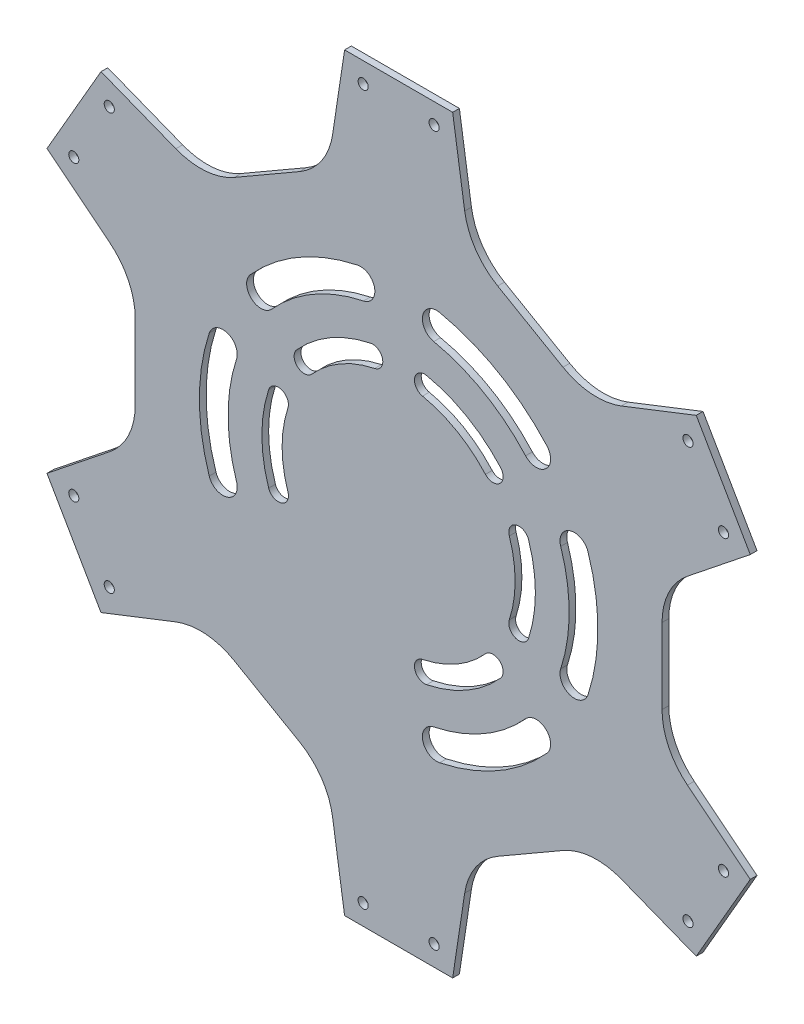
from build123d import *

# Parameters (mm, degrees)
BOSS_EXTRUDE1_DEPTH = 2
CUT_EXTRUDE4_REACH  = 4
CUT_EXTRUDE5_REACH  = 4
SKETCH6_R           = 1.5


with BuildPart() as part:
    # Sketch1 → Boss-Extrude1 (new body)
    with BuildSketch(Plane.XY):
        with BuildLine():
            Line((88.12881982, 222), (84.568261253, 198.459214885))
            ThreePointArc((84.568261253, 198.459214885), (81.315061134, 190.17956792), (74.793177049, 184.129700743))
            Line((74.793177049, 184.129700743), (55.464462591, 172.970262248))
            ThreePointArc((55.464462591, 172.970262248), (46.964181884, 170.347078538), (38.167197219, 171.669548074))
            Line((38.167197219, 171.669548074), (16, 180.356406461))
            Line((16, 180.356406461), (0, 152.643593539))
            Line((0, 152.643593539), (18.606638651, 137.789666811))
            ThreePointArc((18.606638651, 137.789666811), (24.150423198, 130.832489382), (26.12881982, 122.159438495))
            Line((26.12881982, 122.159438495), (26.12881982, 99.840561505))
            ThreePointArc((26.12881982, 99.840561505), (24.150423198, 91.167510618), (18.606638651, 84.210333189))
            Line((18.606638651, 84.210333189), (0, 69.356406461))
            Line((0, 69.356406461), (16, 41.643593539))
            Line((16, 41.643593539), (38.167197219, 50.330451926))
            ThreePointArc((38.167197219, 50.330451926), (46.964181884, 51.652921462), (55.464462591, 49.029737752))
            Line((55.464462591, 49.029737752), (74.793177049, 37.870299257))
            ThreePointArc((74.793177049, 37.870299257), (81.315061134, 31.82043208), (84.568261253, 23.540785115))
            Line((84.568261253, 23.540785115), (88.12881982, 0))
            Line((88.12881982, 0), (120.12881982, 0))
            Line((120.12881982, 0), (123.689378387, 23.540785115))
            ThreePointArc((123.689378387, 23.540785115), (126.942578506, 31.82043208), (133.464462591, 37.870299257))
            Line((133.464462591, 37.870299257), (152.793177049, 49.029737752))
            ThreePointArc((152.793177049, 49.029737752), (161.293457756, 51.652921462), (170.090442422, 50.330451926))
            Line((170.090442422, 50.330451926), (192.25763964, 41.643593539))
            Line((192.25763964, 41.643593539), (208.25763964, 69.356406461))
            Line((208.25763964, 69.356406461), (189.651000989, 84.210333189))
            ThreePointArc((189.651000989, 84.210333189), (184.107216442, 91.167510618), (182.12881982, 99.840561505))
            Line((182.12881982, 99.840561505), (182.12881982, 122.159438495))
            ThreePointArc((182.12881982, 122.159438495), (184.107216442, 130.832489382), (189.651000989, 137.789666811))
            Line((189.651000989, 137.789666811), (208.25763964, 152.643593539))
            Line((208.25763964, 152.643593539), (192.25763964, 180.356406461))
            Line((192.25763964, 180.356406461), (170.090442422, 171.669548074))
            ThreePointArc((170.090442422, 171.669548074), (161.293457756, 170.347078538), (152.793177049, 172.970262248))
            Line((152.793177049, 172.970262248), (133.464462591, 184.129700743))
            ThreePointArc((133.464462591, 184.129700743), (126.942578506, 190.17956792), (123.689378387, 198.459214885))
            Line((123.689378387, 198.459214885), (120.12881982, 222))
            Line((120.12881982, 222), (88.12881982, 222))
        make_face()
    extrude(amount=BOSS_EXTRUDE1_DEPTH)

    # Sketch5 → Cut-Extrude4 (cut, up to next)
    with BuildSketch(Plane.XY.offset(2), mode=Mode.PRIVATE) as cut_extrude4_sk1:
        with BuildLine():
            ThreePointArc((134.30285859, 138.01439217), (124.37881982, 146.074028853), (112.436950322, 150.638680195))
            ThreePointArc((112.436950322, 150.638680195), (108.885334715, 148.317898736), (111.206116174, 144.766283129))
            ThreePointArc((111.206116174, 144.766283129), (121.37881982, 140.877876431), (129.832630624, 134.012259997))
            ThreePointArc((129.832630624, 134.012259997), (134.068810694, 133.7782121), (134.30285859, 138.01439217))
        make_face()
    cut_extrude4_tool1 = extrude(cut_extrude4_sk1.sketch, amount=-CUT_EXTRUDE4_REACH, mode=Mode.PRIVATE) & part.part
    add(cut_extrude4_tool1.solids().sort_by_distance((122.463529, 142.756648, 2))[0], mode=Mode.SUBTRACT)
    # Sketch5 → Cut-Extrude4 (cut, up to next)
    with BuildSketch(Plane.XY.offset(2), mode=Mode.PRIVATE) as cut_extrude4_sk2:
        with BuildLine():
            ThreePointArc((116.289083676, 168.733248505), (111.254381514, 165.450448764), (114.537181256, 160.415746602))
            ThreePointArc((114.537181256, 160.415746602), (129.37881982, 154.734282891), (141.719931007, 144.721778716))
            ThreePointArc((141.719931007, 144.721778716), (147.72151085, 144.396141825), (148.047147741, 150.397721668))
            ThreePointArc((148.047147741, 150.397721668), (133.62881982, 162.095498823), (116.289083676, 168.733248505))
        make_face()
    cut_extrude4_tool2 = extrude(cut_extrude4_sk2.sketch, amount=-CUT_EXTRUDE4_REACH, mode=Mode.PRIVATE) & part.part
    add(cut_extrude4_tool2.solids().sort_by_distance((130.90458, 157.376977, 2))[0], mode=Mode.SUBTRACT)
    # Sketch5 → Cut-Extrude4 (cut, up to next)
    with BuildSketch(Plane.XY.offset(2), mode=Mode.PRIVATE) as cut_extrude4_sk3:
        with BuildLine():
            ThreePointArc((136.909926978, 100.245976868), (138.62881982, 111), (136.909926978, 121.754023132))
            ThreePointArc((136.909926978, 121.754023132), (138.825325589, 125.539686636), (142.610989092, 123.624288025))
            ThreePointArc((142.610989092, 123.624288025), (144.62881982, 111), (142.610989092, 98.375711975))
            ThreePointArc((142.610989092, 98.375711975), (138.825325589, 96.460313364), (136.909926978, 100.245976868))
        make_face()
    cut_extrude4_tool3 = extrude(cut_extrude4_sk3.sketch, amount=-CUT_EXTRUDE4_REACH, mode=Mode.PRIVATE) & part.part
    add(cut_extrude4_tool3.solids().sort_by_distance((140.798238, 111, 2))[0], mode=Mode.SUBTRACT)
    # Sketch5 → Cut-Extrude4 (cut, up to next)
    with BuildSketch(Plane.XY.offset(2), mode=Mode.PRIVATE) as cut_extrude4_sk4:
        with BuildLine():
            ThreePointArc((152.128292442, 95.306032114), (154.62881982, 111), (152.128292442, 126.693967886))
            ThreePointArc((152.128292442, 126.693967886), (154.847072544, 132.054306939), (160.207411596, 129.335526837))
            ThreePointArc((160.207411596, 129.335526837), (163.12881982, 111), (160.207411596, 92.664473163))
            ThreePointArc((160.207411596, 92.664473163), (154.847072544, 89.945693061), (152.128292442, 95.306032114))
        make_face()
    cut_extrude4_tool4 = extrude(cut_extrude4_sk4.sketch, amount=-CUT_EXTRUDE4_REACH, mode=Mode.PRIVATE) & part.part
    add(cut_extrude4_tool4.solids().sort_by_distance((157.68034, 111, 2))[0], mode=Mode.SUBTRACT)
    # Sketch5 → Cut-Extrude4 (cut, up to next)
    with BuildSketch(Plane.XY.offset(2), mode=Mode.PRIVATE) as cut_extrude4_sk5:
        with BuildLine():
            ThreePointArc((111.206116174, 77.233716871), (121.37881982, 81.122123569), (129.832630624, 87.987740003))
            ThreePointArc((129.832630624, 87.987740003), (134.068810694, 88.2217879), (134.30285859, 83.98560783))
            ThreePointArc((134.30285859, 83.98560783), (124.37881982, 75.925971147), (112.436950322, 71.361319805))
            ThreePointArc((112.436950322, 71.361319805), (108.885334715, 73.682101264), (111.206116174, 77.233716871))
        make_face()
    cut_extrude4_tool5 = extrude(cut_extrude4_sk5.sketch, amount=-CUT_EXTRUDE4_REACH, mode=Mode.PRIVATE) & part.part
    add(cut_extrude4_tool5.solids().sort_by_distance((122.463529, 79.243352, 2))[0], mode=Mode.SUBTRACT)
    # Sketch5 → Cut-Extrude4 (cut, up to next)
    with BuildSketch(Plane.XY.offset(2), mode=Mode.PRIVATE) as cut_extrude4_sk6:
        with BuildLine():
            ThreePointArc((114.537181256, 61.584253398), (129.37881982, 67.265717109), (141.719931007, 77.278221284))
            ThreePointArc((141.719931007, 77.278221284), (147.72151085, 77.603858175), (148.047147741, 71.602278332))
            ThreePointArc((148.047147741, 71.602278332), (133.62881982, 59.904501177), (116.289083676, 53.266751495))
            ThreePointArc((116.289083676, 53.266751495), (111.254381514, 56.549551236), (114.537181256, 61.584253398))
        make_face()
    cut_extrude4_tool6 = extrude(cut_extrude4_sk6.sketch, amount=-CUT_EXTRUDE4_REACH, mode=Mode.PRIVATE) & part.part
    add(cut_extrude4_tool6.solids().sort_by_distance((130.90458, 64.623023, 2))[0], mode=Mode.SUBTRACT)
    # Sketch5 → Cut-Extrude4 (cut, up to next)
    with BuildSketch(Plane.XY.offset(2), mode=Mode.PRIVATE) as cut_extrude4_sk7:
        with BuildLine():
            ThreePointArc((71.347712663, 121.754023132), (69.62881982, 111), (71.347712663, 100.245976868))
            ThreePointArc((71.347712663, 100.245976868), (69.432314052, 96.460313364), (65.646650548, 98.375711975))
            ThreePointArc((65.646650548, 98.375711975), (63.62881982, 111), (65.646650548, 123.624288025))
            ThreePointArc((65.646650548, 123.624288025), (69.432314052, 125.539686636), (71.347712663, 121.754023132))
        make_face()
    cut_extrude4_tool7 = extrude(cut_extrude4_sk7.sketch, amount=-CUT_EXTRUDE4_REACH, mode=Mode.PRIVATE) & part.part
    add(cut_extrude4_tool7.solids().sort_by_distance((67.459401, 111, 2))[0], mode=Mode.SUBTRACT)
    # Sketch5 → Cut-Extrude4 (cut, up to next)
    with BuildSketch(Plane.XY.offset(2), mode=Mode.PRIVATE) as cut_extrude4_sk8:
        with BuildLine():
            ThreePointArc((56.129347198, 126.693967886), (53.62881982, 111), (56.129347198, 95.306032114))
            ThreePointArc((56.129347198, 95.306032114), (53.410567096, 89.945693061), (48.050228044, 92.664473163))
            ThreePointArc((48.050228044, 92.664473163), (45.12881982, 111), (48.050228044, 129.335526837))
            ThreePointArc((48.050228044, 129.335526837), (53.410567096, 132.054306939), (56.129347198, 126.693967886))
        make_face()
    cut_extrude4_tool8 = extrude(cut_extrude4_sk8.sketch, amount=-CUT_EXTRUDE4_REACH, mode=Mode.PRIVATE) & part.part
    add(cut_extrude4_tool8.solids().sort_by_distance((50.5773, 111, 2))[0], mode=Mode.SUBTRACT)
    # Sketch5 → Cut-Extrude4 (cut, up to next)
    with BuildSketch(Plane.XY.offset(2), mode=Mode.PRIVATE) as cut_extrude4_sk9:
        with BuildLine():
            ThreePointArc((97.051523467, 144.766283129), (86.87881982, 140.877876431), (78.425009016, 134.012259997))
            ThreePointArc((78.425009016, 134.012259997), (74.188828946, 133.7782121), (73.95478105, 138.01439217))
            ThreePointArc((73.95478105, 138.01439217), (83.87881982, 146.074028853), (95.820689318, 150.638680195))
            ThreePointArc((95.820689318, 150.638680195), (99.372304925, 148.317898736), (97.051523467, 144.766283129))
        make_face()
    cut_extrude4_tool9 = extrude(cut_extrude4_sk9.sketch, amount=-CUT_EXTRUDE4_REACH, mode=Mode.PRIVATE) & part.part
    add(cut_extrude4_tool9.solids().sort_by_distance((85.794111, 142.756648, 2))[0], mode=Mode.SUBTRACT)
    # Sketch5 → Cut-Extrude4 (cut, up to next)
    with BuildSketch(Plane.XY.offset(2), mode=Mode.PRIVATE) as cut_extrude4_sk10:
        with BuildLine():
            ThreePointArc((93.720458384, 160.415746602), (78.87881982, 154.734282891), (66.537708634, 144.721778716))
            ThreePointArc((66.537708634, 144.721778716), (60.53612879, 144.396141825), (60.210491899, 150.397721668))
            ThreePointArc((60.210491899, 150.397721668), (74.62881982, 162.095498823), (91.968555965, 168.733248505))
            ThreePointArc((91.968555965, 168.733248505), (97.003258126, 165.450448764), (93.720458384, 160.415746602))
        make_face()
    cut_extrude4_tool10 = extrude(cut_extrude4_sk10.sketch, amount=-CUT_EXTRUDE4_REACH, mode=Mode.PRIVATE) & part.part
    add(cut_extrude4_tool10.solids().sort_by_distance((77.35306, 157.376977, 2))[0], mode=Mode.SUBTRACT)

    # Sketch6 → Cut-Extrude5 (cut, up to next)
    with BuildSketch(Plane.XY.offset(2), mode=Mode.PRIVATE) as cut_extrude5_sk1:
        with Locations((93.62881982, 216)):
            Circle(SKETCH6_R)
    cut_extrude5_tool1 = extrude(cut_extrude5_sk1.sketch, amount=-CUT_EXTRUDE5_REACH, mode=Mode.PRIVATE) & part.part
    add(cut_extrude5_tool1.solids().sort_by_distance((93.62882, 216, 2))[0], mode=Mode.SUBTRACT)
    # Sketch6 → Cut-Extrude5 (cut, up to next)
    with BuildSketch(Plane.XY.offset(2), mode=Mode.PRIVATE) as cut_extrude5_sk2:
        with Locations((114.62881982, 216)):
            Circle(SKETCH6_R)
    cut_extrude5_tool2 = extrude(cut_extrude5_sk2.sketch, amount=-CUT_EXTRUDE5_REACH, mode=Mode.PRIVATE) & part.part
    add(cut_extrude5_tool2.solids().sort_by_distance((114.62882, 216, 2))[0], mode=Mode.SUBTRACT)
    # Sketch6 → Cut-Extrude5 (cut, up to next)
    with BuildSketch(Plane.XY.offset(2), mode=Mode.PRIVATE) as cut_extrude5_sk3:
        with Locations((93.62881982, 6)):
            Circle(SKETCH6_R)
    cut_extrude5_tool3 = extrude(cut_extrude5_sk3.sketch, amount=-CUT_EXTRUDE5_REACH, mode=Mode.PRIVATE) & part.part
    add(cut_extrude5_tool3.solids().sort_by_distance((93.62882, 6, 2))[0], mode=Mode.SUBTRACT)
    # Sketch6 → Cut-Extrude5 (cut, up to next)
    with BuildSketch(Plane.XY.offset(2), mode=Mode.PRIVATE) as cut_extrude5_sk4:
        with Locations((114.62881982, 6)):
            Circle(SKETCH6_R)
    cut_extrude5_tool4 = extrude(cut_extrude5_sk4.sketch, amount=-CUT_EXTRUDE5_REACH, mode=Mode.PRIVATE) & part.part
    add(cut_extrude5_tool4.solids().sort_by_distance((114.62882, 6, 2))[0], mode=Mode.SUBTRACT)
    # Sketch6 → Cut-Extrude5 (cut, up to next)
    with BuildSketch(Plane.XY.offset(2), mode=Mode.PRIVATE) as cut_extrude5_sk5:
        with Locations((7.946152423, 67.59326674)):
            Circle(SKETCH6_R)
    cut_extrude5_tool5 = extrude(cut_extrude5_sk5.sketch, amount=-CUT_EXTRUDE5_REACH, mode=Mode.PRIVATE) & part.part
    add(cut_extrude5_tool5.solids().sort_by_distance((7.946152, 67.593267, 2))[0], mode=Mode.SUBTRACT)
    # Sketch6 → Cut-Extrude5 (cut, up to next)
    with BuildSketch(Plane.XY.offset(2), mode=Mode.PRIVATE) as cut_extrude5_sk6:
        with Locations((18.446152423, 49.40673326)):
            Circle(SKETCH6_R)
    cut_extrude5_tool6 = extrude(cut_extrude5_sk6.sketch, amount=-CUT_EXTRUDE5_REACH, mode=Mode.PRIVATE) & part.part
    add(cut_extrude5_tool6.solids().sort_by_distance((18.446152, 49.406733, 2))[0], mode=Mode.SUBTRACT)
    # Sketch6 → Cut-Extrude5 (cut, up to next)
    with BuildSketch(Plane.XY.offset(2), mode=Mode.PRIVATE) as cut_extrude5_sk7:
        with Locations((7.946152423, 154.40673326)):
            Circle(SKETCH6_R)
    cut_extrude5_tool7 = extrude(cut_extrude5_sk7.sketch, amount=-CUT_EXTRUDE5_REACH, mode=Mode.PRIVATE) & part.part
    add(cut_extrude5_tool7.solids().sort_by_distance((7.946152, 154.406733, 2))[0], mode=Mode.SUBTRACT)
    # Sketch6 → Cut-Extrude5 (cut, up to next)
    with BuildSketch(Plane.XY.offset(2), mode=Mode.PRIVATE) as cut_extrude5_sk8:
        with Locations((18.446152423, 172.59326674)):
            Circle(SKETCH6_R)
    cut_extrude5_tool8 = extrude(cut_extrude5_sk8.sketch, amount=-CUT_EXTRUDE5_REACH, mode=Mode.PRIVATE) & part.part
    add(cut_extrude5_tool8.solids().sort_by_distance((18.446152, 172.593267, 2))[0], mode=Mode.SUBTRACT)
    # Sketch6 → Cut-Extrude5 (cut, up to next)
    with BuildSketch(Plane.XY.offset(2), mode=Mode.PRIVATE) as cut_extrude5_sk9:
        with Locations((189.811487217, 172.59326674)):
            Circle(SKETCH6_R)
    cut_extrude5_tool9 = extrude(cut_extrude5_sk9.sketch, amount=-CUT_EXTRUDE5_REACH, mode=Mode.PRIVATE) & part.part
    add(cut_extrude5_tool9.solids().sort_by_distance((189.811487, 172.593267, 2))[0], mode=Mode.SUBTRACT)
    # Sketch6 → Cut-Extrude5 (cut, up to next)
    with BuildSketch(Plane.XY.offset(2), mode=Mode.PRIVATE) as cut_extrude5_sk10:
        with Locations((200.311487217, 154.40673326)):
            Circle(SKETCH6_R)
    cut_extrude5_tool10 = extrude(cut_extrude5_sk10.sketch, amount=-CUT_EXTRUDE5_REACH, mode=Mode.PRIVATE) & part.part
    add(cut_extrude5_tool10.solids().sort_by_distance((200.311487, 154.406733, 2))[0], mode=Mode.SUBTRACT)
    # Sketch6 → Cut-Extrude5 (cut, up to next)
    with BuildSketch(Plane.XY.offset(2), mode=Mode.PRIVATE) as cut_extrude5_sk11:
        with Locations((200.311487217, 67.59326674)):
            Circle(SKETCH6_R)
    cut_extrude5_tool11 = extrude(cut_extrude5_sk11.sketch, amount=-CUT_EXTRUDE5_REACH, mode=Mode.PRIVATE) & part.part
    add(cut_extrude5_tool11.solids().sort_by_distance((200.311487, 67.593267, 2))[0], mode=Mode.SUBTRACT)
    # Sketch6 → Cut-Extrude5 (cut, up to next)
    with BuildSketch(Plane.XY.offset(2), mode=Mode.PRIVATE) as cut_extrude5_sk12:
        with Locations((189.811487217, 49.40673326)):
            Circle(SKETCH6_R)
    cut_extrude5_tool12 = extrude(cut_extrude5_sk12.sketch, amount=-CUT_EXTRUDE5_REACH, mode=Mode.PRIVATE) & part.part
    add(cut_extrude5_tool12.solids().sort_by_distance((189.811487, 49.406733, 2))[0], mode=Mode.SUBTRACT)


solid = part.part
